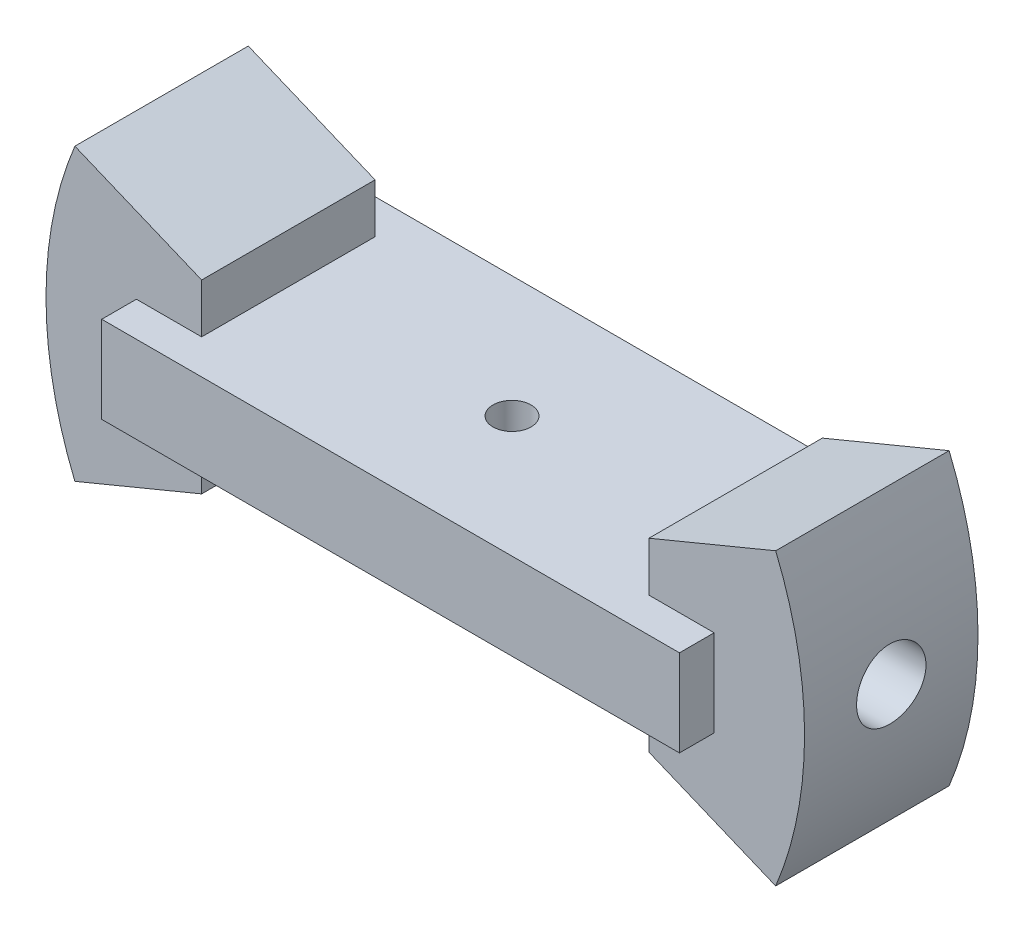
from build123d import *

# Parameters (mm, degrees)
BOSS_EXTRUDE1_DEPTH   = 5
BOSS_EXTRUDE1_2_DEPTH = 5
SKETCH1_3_W           = 33.311527072
SKETCH1_3_H           = 5
BOSS_EXTRUDE2_DEPTH   = 7
CUT_EXTRUDE1_REACH    = 27.404
SKETCH2_R             = 1.1
SKETCH3_R             = 2
CUT_EXTRUDE2_DEPTH    = 4


with BuildPart() as part:
    # Sketch1 → Boss-Extrude1 (new, symmetric)
    with BuildSketch(Plane.XY):
        with BuildLine():
            Line((-12.89486278, 5.341227048), (-20.204359293, 8.368919638))
            ThreePointArc((-20.204359293, 8.368919638), (-21.869040911, 0), (-20.204359293, -8.368919638))
            Line((-20.204359293, -8.368919638), (-12.89486278, -5.341227048))
            Line((-12.89486278, -5.341227048), (-12.89486278, -2.5))
            Line((-12.89486278, -2.5), (-16.655763536, -2.5))
            Line((-16.655763536, -2.5), (-16.655763536, 2.5))
            Line((-16.655763536, 2.5), (-12.89486278, 2.5))
            Line((-12.89486278, 2.5), (-12.89486278, 5.341227048))
        make_face()
    extrude(amount=BOSS_EXTRUDE1_DEPTH, both=True)



with BuildPart() as body_2:
    # Sketch1 → Boss-Extrude1 2 (new, symmetric)
    with BuildSketch(Plane.XY):
        with BuildLine():
            Line((12.89486278, 5.341227048), (12.89486278, 2.5))
            Line((12.89486278, 2.5), (16.655763536, 2.5))
            Line((16.655763536, 2.5), (16.655763536, -2.5))
            Line((16.655763536, -2.5), (12.89486278, -2.5))
            Line((12.89486278, -2.5), (12.89486278, -5.341227048))
            Line((12.89486278, -5.341227048), (20.204359293, -8.368919638))
            ThreePointArc((20.204359293, -8.368919638), (21.869040911, 0), (20.204359293, 8.368919638))
            Line((20.204359293, 8.368919638), (12.89486278, 5.341227048))
        make_face()
    extrude(amount=BOSS_EXTRUDE1_2_DEPTH, both=True)


with BuildPart() as part_1:
    add(part.part)

    add(body_2.part)  # Boss-Extrude2 merges body 2
    # Sketch1_3 → Boss-Extrude2 (add, symmetric)
    with BuildSketch(Plane.XY):
        Rectangle(SKETCH1_3_W, SKETCH1_3_H)
    extrude(amount=BOSS_EXTRUDE2_DEPTH, both=True)

    # Sketch2 → Cut-Extrude1 (cut, up to next)
    with BuildSketch(Plane(origin=(0, 2.5, 0), x_dir=(1, 0, 0), z_dir=(0, 1, 0)), mode=Mode.PRIVATE) as cut_extrude1_sk1:
        Circle(SKETCH2_R)
    cut_extrude1_tool1 = extrude(cut_extrude1_sk1.sketch, amount=-CUT_EXTRUDE1_REACH, mode=Mode.PRIVATE) & part_1.part
    add(cut_extrude1_tool1.solids().sort_by_distance((0, 2.5, 0))[0], mode=Mode.SUBTRACT)

    # Sketch3 → Cut-Extrude2 (cut)
    with BuildSketch(Plane(origin=(21.869040911, 0, 0), x_dir=(0, 0, -1), z_dir=(1, 0, 0))):
        Circle(SKETCH3_R)
    cut_extrude2 = extrude(amount=-CUT_EXTRUDE2_DEPTH, mode=Mode.SUBTRACT)

    # Mirror1: Cut-Extrude2 across plane
    add(cut_extrude2.mirror(Plane(origin=(0, 0, 0), x_dir=(0, 0, 1), z_dir=(1, 0, 0))), mode=Mode.SUBTRACT)


solid = part_1.part
